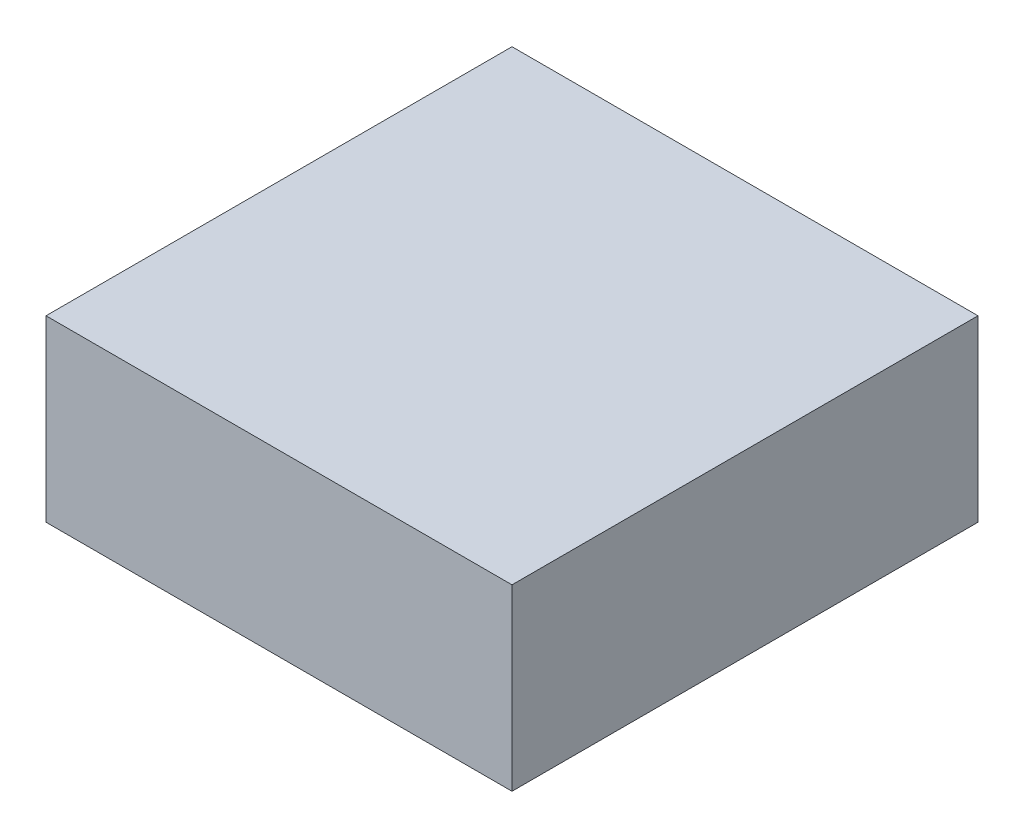
from build123d import *

# Parameters (mm, degrees)
BOSS_EXTRUDE1_DEPTH = 1372
SKETCH4_W           = 14000
SKETCH4_H           = 14000
SKETCH4_R           = 5000
BOSS_EXTRUDE2_DEPTH = 4000


with BuildPart() as part:
    # Sketch2 → Revolve2 (revolve)
    with BuildSketch(Plane.XY):
        Polygon((-2750, 2000), (-7000, 2000), (-7000, 3372), (0, 3372), (0, 3332), (-2123.381318695, 3332), (-2750, 2732.374065947), align=None)
    revolve(axis=Axis((0, 3520.44, 0), (0, -1, 0)))

    # Sketch3 → Boss-Extrude1 (add)
    with BuildSketch(Plane(origin=(0, 3372, 0), x_dir=(1, 0, 0), z_dir=(0, 1, 0))):
        with BuildLine():
            ThreePointArc((7.996e-06, -7000), (-4949.747456115, -4949.747480497), (-7000, -2.6486e-05))
            Line((-7000, -2.6486e-05), (-7000, -7000))
            Line((-7000, -7000), (7.996e-06, -7000))
        make_face()
        with BuildLine():
            Line((-2.0497e-05, 7000), (-7000, 7000))
            Line((-7000, 7000), (-7000, -2.6486e-05))
            ThreePointArc((-7000, -2.6486e-05), (-4949.747484916, 4949.747451695), (-2.0497e-05, 7000))
        make_face()
        with BuildLine():
            Line((7000, 7000), (-2.0497e-05, 7000))
            ThreePointArc((-2.0497e-05, 7000), (4949.747461059, 4949.747475552), (7000, 0))
            Line((7000, 0), (7000, 7000))
        make_face()
        with BuildLine():
            Line((7000, -7000), (7000, 0))
            ThreePointArc((7000, 0), (4949.747471133, -4949.747465479), (7.996e-06, -7000))
            Line((7.996e-06, -7000), (7000, -7000))
        make_face()
    extrude(amount=-BOSS_EXTRUDE1_DEPTH)

    # Sketch4 → Boss-Extrude2 (add)
    with BuildSketch(Plane.XZ.offset(-2000)):
        Rectangle(SKETCH4_W, SKETCH4_H)
        Circle(SKETCH4_R, mode=Mode.SUBTRACT)
    extrude(amount=BOSS_EXTRUDE2_DEPTH)


solid = part.part
